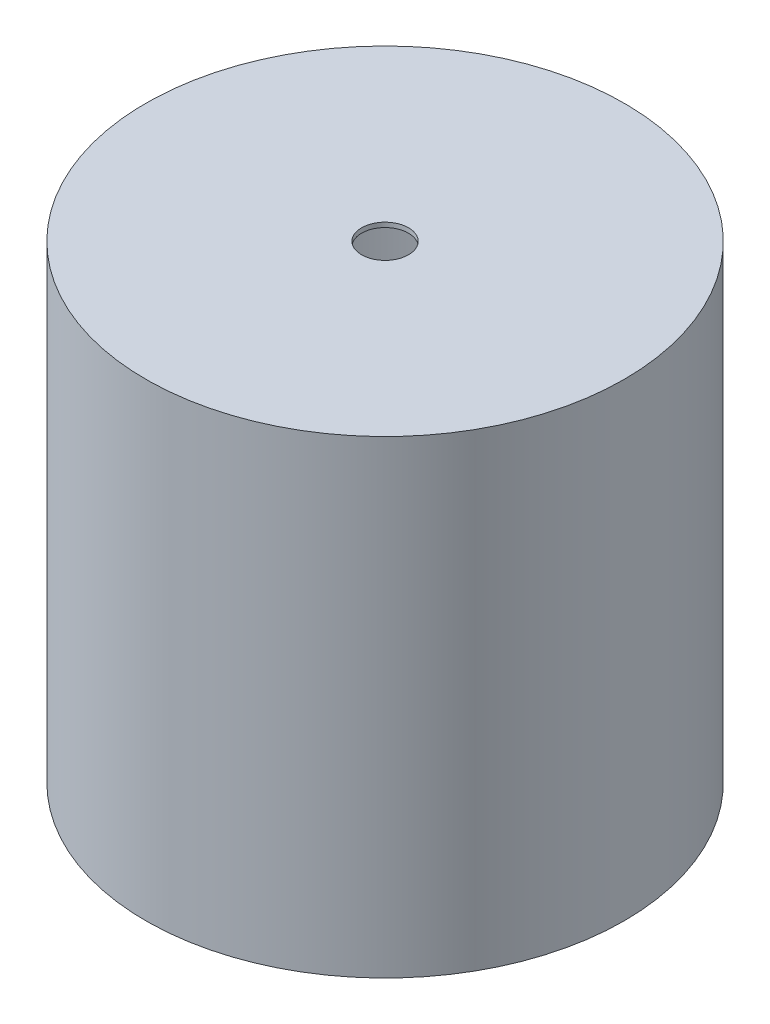
from build123d import *

# Parameters (mm, degrees)
SKETCH1_R               = 51
SKETCH1_R_2             = 50
EXTRUDE_THIN1_DEPTH     = 100
SKETCH1_2_R             = 50
BOSS_EXTRUDE1_DEPTH     = 1
LPATTERN1_COUNT         = 2
LPATTERN1_PITCH         = 99
SKETCH3_R               = 5
CUT_EXTRUDE1_DEPTH      = 124.296390864
SKETCH3_2_R             = 6
SKETCH3_2_R_2           = 5
EXTRUDE_THIN2_DEPTH     = 10
CUT_EXTRUDE2_DEPTH      = 20
CUT_EXTRUDE2_DEPTH_BACK = 20
SKETCH5_R               = 2.5


with BuildPart() as part:
    # Sketch1 → Extrude-Thin1 (new body)
    with BuildSketch(Plane(origin=(0, 0, 0), x_dir=(1, 0, 0), z_dir=(0, 1, 0))):
        Circle(SKETCH1_R)
        Circle(SKETCH1_R_2, mode=Mode.SUBTRACT)
    extrude(amount=EXTRUDE_THIN1_DEPTH)

    # Sketch1_2 → Boss-Extrude1 (add)
    with BuildSketch(Plane(origin=(0, 0, 0), x_dir=(1, 0, 0), z_dir=(0, 1, 0))):
        Circle(SKETCH1_2_R)
    boss_extrude1 = extrude(amount=BOSS_EXTRUDE1_DEPTH)

    # LPattern1: Boss-Extrude1 ×2
    with Locations(*[(0, i * LPATTERN1_PITCH, 0) for i in range(1, LPATTERN1_COUNT)]):
        add(boss_extrude1)

    # Sketch3 → Cut-Extrude1 (cut, through all)
    with BuildSketch(Plane.XZ):
        Circle(SKETCH3_R)
    extrude(amount=-CUT_EXTRUDE1_DEPTH, mode=Mode.SUBTRACT)

    # Sketch3_2 → Extrude-Thin2 (add)
    with BuildSketch(Plane.XZ):
        Circle(SKETCH3_2_R)
        Circle(SKETCH3_2_R_2, mode=Mode.SUBTRACT)
    extrude(amount=-EXTRUDE_THIN2_DEPTH)

    # Sketch5 → Cut-Extrude2 (cut, two sides: drawn at the far end of the back side and taken through both)
    with BuildSketch(Plane.XY.offset(-CUT_EXTRUDE2_DEPTH_BACK)):
        with Locations((0, 5)):
            Circle(SKETCH5_R)
    extrude(amount=CUT_EXTRUDE2_DEPTH + CUT_EXTRUDE2_DEPTH_BACK, mode=Mode.SUBTRACT)


solid = part.part
